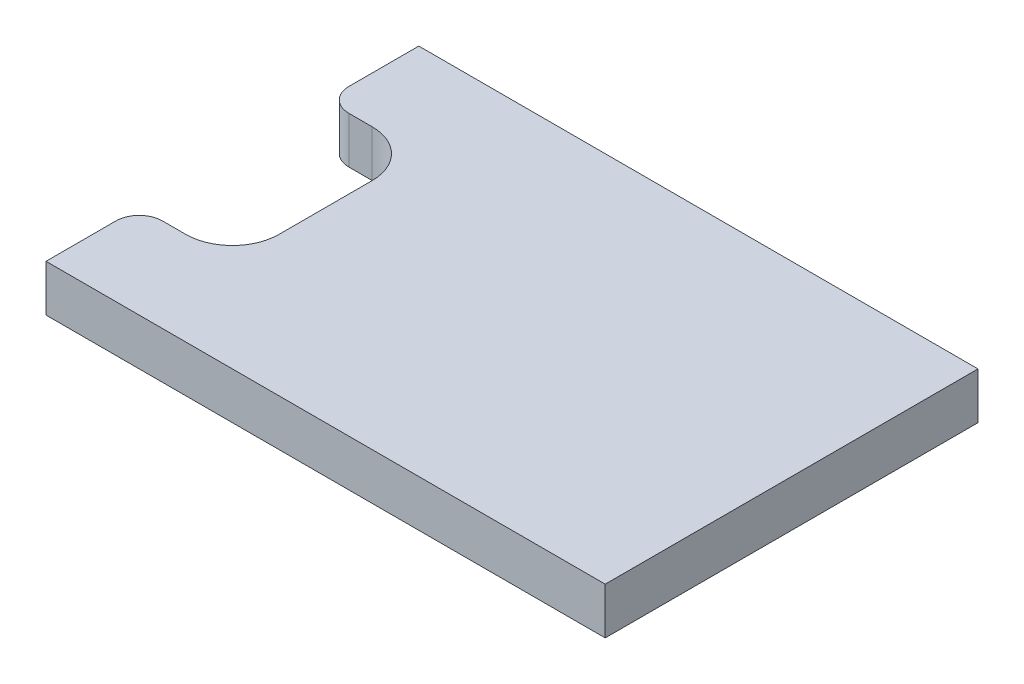
from build123d import *

# Parameters (mm, degrees)
SKETCH1_W           = 120
SKETCH1_H           = 80
BOSS_EXTRUDE1_DEPTH = 10
SKETCH2_W           = 20
SKETCH2_H           = 40
CUT_EXTRUDE1_DEPTH  = 11
FILLET1_R           = 10
FILLET2_R           = 5


with BuildPart() as part:
    # Sketch1 → Boss-Extrude1 (new body)
    with BuildSketch(Plane.XZ.offset(150)):
        with Locations((-26.489460092, -13.07873573)):
            Rectangle(SKETCH1_W, SKETCH1_H)
    extrude(amount=BOSS_EXTRUDE1_DEPTH)

    # Sketch2 → Cut-Extrude1 (cut, through all)
    with BuildSketch(Plane(origin=(0, -150, 0), x_dir=(1, 0, 0), z_dir=(0, 1, 0))):
        with Locations((-76.489460092, 13.07873573)):
            Rectangle(SKETCH2_W, SKETCH2_H)
    extrude(amount=-CUT_EXTRUDE1_DEPTH, mode=Mode.SUBTRACT)

    # Fillet1
    fillet1_edges = [part.edges().sort_by_distance(p)[0] for p in [
        (-66.489460092, -155, -33.07873573),
        (-66.489460092, -155, 6.92126427),
    ]]
    fillet(fillet1_edges, radius=FILLET1_R)

    # Fillet2
    fillet2_edges = [part.edges().sort_by_distance(p)[0] for p in [
        (-86.489460092, -155, 6.92126427),
        (-86.489460092, -155, -33.07873573),
    ]]
    fillet(fillet2_edges, radius=FILLET2_R)


solid = part.part
